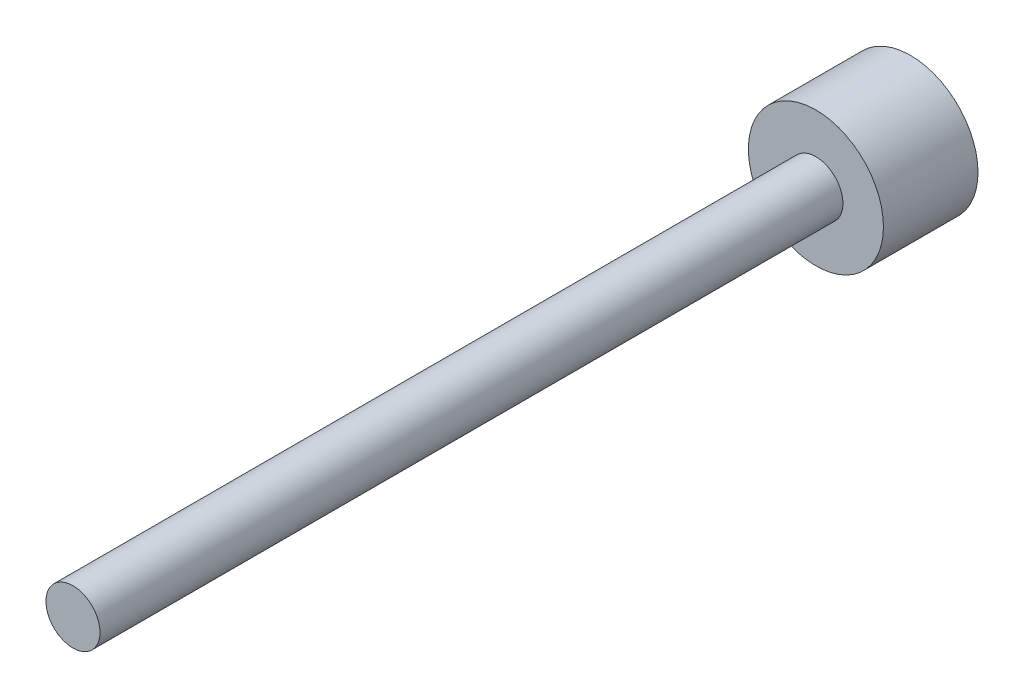
from build123d import *

# Parameters (mm, degrees)
SKETCH1_R           = 6.35
BOSS_EXTRUDE1_DEPTH = 8.89
SKETCH2_R           = 2.54
BOSS_EXTRUDE2_DEPTH = 69.85


with BuildPart() as part:
    # Sketch1 → Boss-Extrude1 (new body)
    with BuildSketch(Plane.XY):
        Circle(SKETCH1_R)
    extrude(amount=BOSS_EXTRUDE1_DEPTH)

    # Sketch2 → Boss-Extrude2 (add)
    with BuildSketch(Plane.XY.offset(8.89)):
        Circle(SKETCH2_R)
    extrude(amount=BOSS_EXTRUDE2_DEPTH)


solid = part.part
